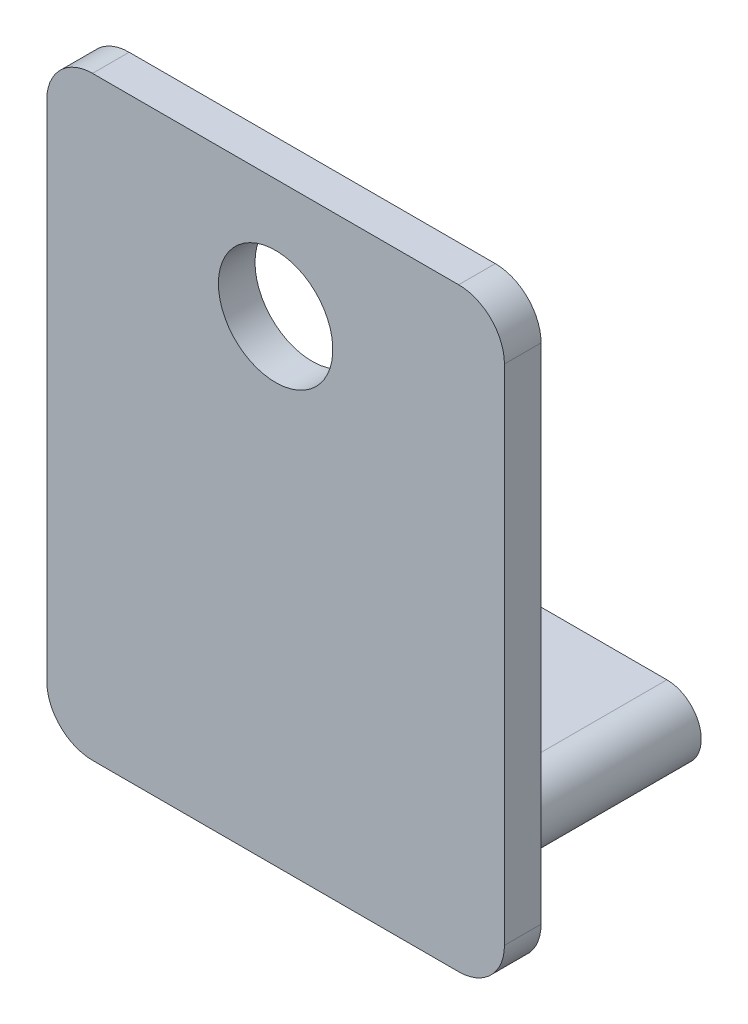
from build123d import *

# Parameters (mm, degrees)
EXTRUDE_1_DEPTH     = 0.8
CUT_EXTRUDE_1_REACH = 2.8
SKETCH_2_R          = 1.25
EXTRUDE_2_DEPTH     = 5


with BuildPart() as part:
    # 草图1 → 凸台-拉伸1 (new body)
    with BuildSketch(Plane.XY):
        with BuildLine():
            Line((-4.76744186, 6.351378938), (3.23255814, 6.351378938))
            ThreePointArc((3.23255814, 6.351378938), (3.939664921, 6.058485719), (4.23255814, 5.351378938))
            Line((4.23255814, 5.351378938), (4.23255814, -5.648621062))
            ThreePointArc((4.23255814, -5.648621062), (3.939664921, -6.355727843), (3.23255814, -6.648621062))
            Line((3.23255814, -6.648621062), (-4.76744186, -6.648621062))
            ThreePointArc((-4.76744186, -6.648621062), (-5.474548642, -6.355727843), (-5.76744186, -5.648621062))
            Line((-5.76744186, -5.648621062), (-5.76744186, 5.351378938))
            ThreePointArc((-5.76744186, 5.351378938), (-5.474548642, 6.058485719), (-4.76744186, 6.351378938))
        make_face()
    extrude(amount=EXTRUDE_1_DEPTH)

    # 草图2 → 切除-拉伸1 (cut, up to next)
    with BuildSketch(Plane(origin=(0, 0, 0), x_dir=(-1, 0, 0), z_dir=(0, 0, -1)), mode=Mode.PRIVATE) as cut_extrude_1_sk1:
        with Locations((0.76744186, 3.751378938)):
            Circle(SKETCH_2_R)
    cut_extrude_1_tool1 = extrude(cut_extrude_1_sk1.sketch, amount=-CUT_EXTRUDE_1_REACH, mode=Mode.PRIVATE) & part.part
    add(cut_extrude_1_tool1.solids().sort_by_distance((-0.767442, 3.751379, 0))[0], mode=Mode.SUBTRACT)

    # 草图3 → 凸台-拉伸2 (add)
    with BuildSketch(Plane(origin=(0, 0, 0), x_dir=(-1, 0, 0), z_dir=(0, 0, -1))):
        with BuildLine():
            Line((-1.98255814, -4.648621062), (3.51744186, -4.648621062))
            ThreePointArc((3.51744186, -4.648621062), (4.26744186, -5.398621062), (3.51744186, -6.148621062))
            Line((3.51744186, -6.148621062), (-1.98255814, -6.148621062))
            ThreePointArc((-1.98255814, -6.148621062), (-2.73255814, -5.398621062), (-1.98255814, -4.648621062))
        make_face()
    extrude(amount=EXTRUDE_2_DEPTH)


solid = part.part
